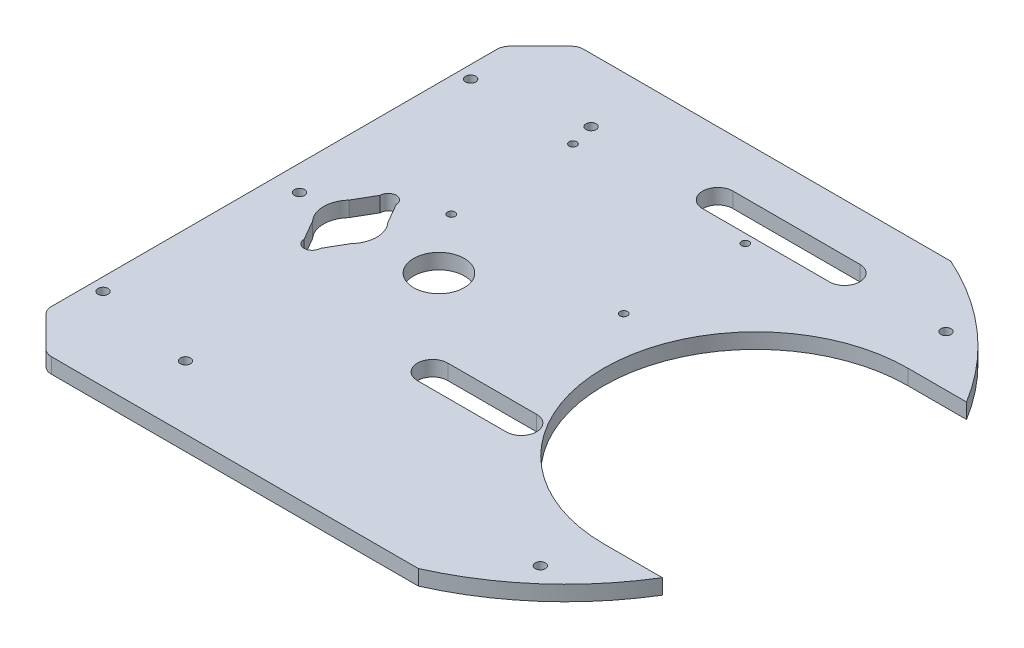
from build123d import *

# Parameters (mm, degrees)
SKETCH1_R           = 2
SKETCH1_R_2         = 10.5
BOSS_EXTRUDE1_DEPTH = 6
SKETCH2_R           = 10
SKETCH2_R_2         = 2
CUT_EXTRUDE2_DEPTH  = 19
BOSS_EXTRUDE2_DEPTH = 6
CHAMFER1_SIZE       = 15
FILLET1_R           = 5
SKETCH4_R           = 1.5
CUT_EXTRUDE3_DEPTH  = 10
SKETCH5_R           = 2
CUT_EXTRUDE4_DEPTH  = 10


with BuildPart() as part:
    # Sketch1 → Boss-Extrude1 (new body)
    with BuildSketch(Plane(origin=(0, 0, 0), x_dir=(1, 0, 0), z_dir=(0, 1, 0))):
        with BuildLine():
            Line((-46.904157598, -105), (46.904157598, -105))
            ThreePointArc((46.904157598, -105), (115, 0), (46.904157598, 105))
            Line((46.904157598, 105), (-46.904157598, 105))
            ThreePointArc((-46.904157598, 105), (-115, 0), (-46.904157598, -105))
        make_face()
        with Locations((-70, 80)):
            Circle(SKETCH1_R, mode=Mode.SUBTRACT)
        with Locations((70, 80)):
            Circle(SKETCH1_R, mode=Mode.SUBTRACT)
        with Locations((70, -80)):
            Circle(SKETCH1_R, mode=Mode.SUBTRACT)
        with Locations((-70, -80)):
            Circle(SKETCH1_R, mode=Mode.SUBTRACT)
        with Locations((-85, 0)):
            Circle(SKETCH1_R_2, mode=Mode.SUBTRACT)
    extrude(amount=BOSS_EXTRUDE1_DEPTH)

    # Sketch2 → Cut-Extrude2 (cut)
    with BuildSketch(Plane.XZ):
        with Locations((-50, 0)):
            Circle(SKETCH2_R)
        with Locations((-105, 0)):
            Circle(SKETCH2_R_2)
        with BuildLine():
            Line((-88.153729078, 15), (-92.680195826, 7.159929613))
            ThreePointArc((-92.680195826, 7.159929613), (-95.5, 0), (-92.680195826, -7.159929613))
            Line((-92.680195826, -7.159929613), (-88.153729078, -15))
            ThreePointArc((-88.153729078, -15), (-85, -18.153729078), (-81.846270922, -15))
            Line((-81.846270922, -15), (-77.319804174, -7.159929613))
            ThreePointArc((-77.319804174, -7.159929613), (-74.5, 0), (-77.319804174, 7.159929613))
            Line((-77.319804174, 7.159929613), (-81.846270922, 15))
            ThreePointArc((-81.846270922, 15), (-85, 18.153729078), (-88.153729078, 15))
        make_face()
        with BuildLine():
            Line((-20, -74), (30, -74))
            ThreePointArc((30, -74), (36, -80), (30, -86))
            Line((30, -86), (-20, -86))
            ThreePointArc((-20, -86), (-26, -80), (-20, -74))
        make_face()
        with BuildLine():
            Line((17.5, 29), (-17.5, 29))
            ThreePointArc((-17.5, 29), (-23.5, 35), (-17.5, 41))
            Line((-17.5, 41), (17.5, 41))
            ThreePointArc((17.5, 41), (23.5, 35), (17.5, 29))
        make_face()
    extrude(amount=-CUT_EXTRUDE2_DEPTH, mode=Mode.SUBTRACT)

    # Sketch3 → Boss-Extrude2 (add)
    with BuildSketch(Plane(origin=(0, 0, 0), x_dir=(-1, 0, 0), z_dir=(0, -1, 0))):
        with BuildLine():
            ThreePointArc((115, 0), (96.485693561, -62.574043645), (46.904157598, -105))
            Line((46.904157598, -105), (115, -105))
            Line((115, -105), (115, 0))
        make_face()
        with BuildLine():
            ThreePointArc((46.904157598, 105), (96.485693561, 62.574043645), (115, 0))
            Line((115, 0), (115, 105))
            Line((115, 105), (46.904157598, 105))
        make_face()
    extrude(amount=-BOSS_EXTRUDE2_DEPTH)

    # Chamfer1
    chamfer1_edges = [part.edges().sort_by_distance(p)[0] for p in [
        (-115, 3, 105),
        (-115, 3, -105),
    ]]
    chamfer(chamfer1_edges, length=CHAMFER1_SIZE)

    # Fillet1
    fillet1_edges = [part.edges().sort_by_distance(p)[0] for p in [
        (-115, 3, 90),
        (-115, 3, -90),
        (-100, 3, -105),
        (-100, 3, 105),
    ]]
    fillet(fillet1_edges, radius=FILLET1_R)

    # Sketch4 → Cut-Extrude3 (cut)
    with BuildSketch(Plane(origin=(0, 6, 0), x_dir=(1, 0, 0), z_dir=(0, 1, 0))):
        with Locations((0.319804174, 22.536233459)):
            Circle(SKETCH4_R)
        with Locations((-67.680195826, 22.536233459)):
            Circle(SKETCH4_R)
        with Locations((-67.680195826, 70.536233459)):
            Circle(SKETCH4_R)
        with Locations((0.319804174, 70.536233459)):
            Circle(SKETCH4_R)
        with BuildLine():
            Line((115, -60), (75, -60))
            ThreePointArc((75, -60), (15, 0), (75, 60))
            Line((75, 60), (115, 60))
            Line((115, 60), (115, -60))
        make_face()
    extrude(amount=-CUT_EXTRUDE3_DEPTH, mode=Mode.SUBTRACT)

    # Sketch5 → Cut-Extrude4 (cut)
    with BuildSketch(Plane(origin=(0, 6, 0), x_dir=(1, 0, 0), z_dir=(0, 1, 0))):
        with Locations((-110, -72.5)):
            Circle(SKETCH5_R)
        with Locations((-110, 72.5)):
            Circle(SKETCH5_R)
    extrude(amount=-CUT_EXTRUDE4_DEPTH, mode=Mode.SUBTRACT)


solid = part.part
